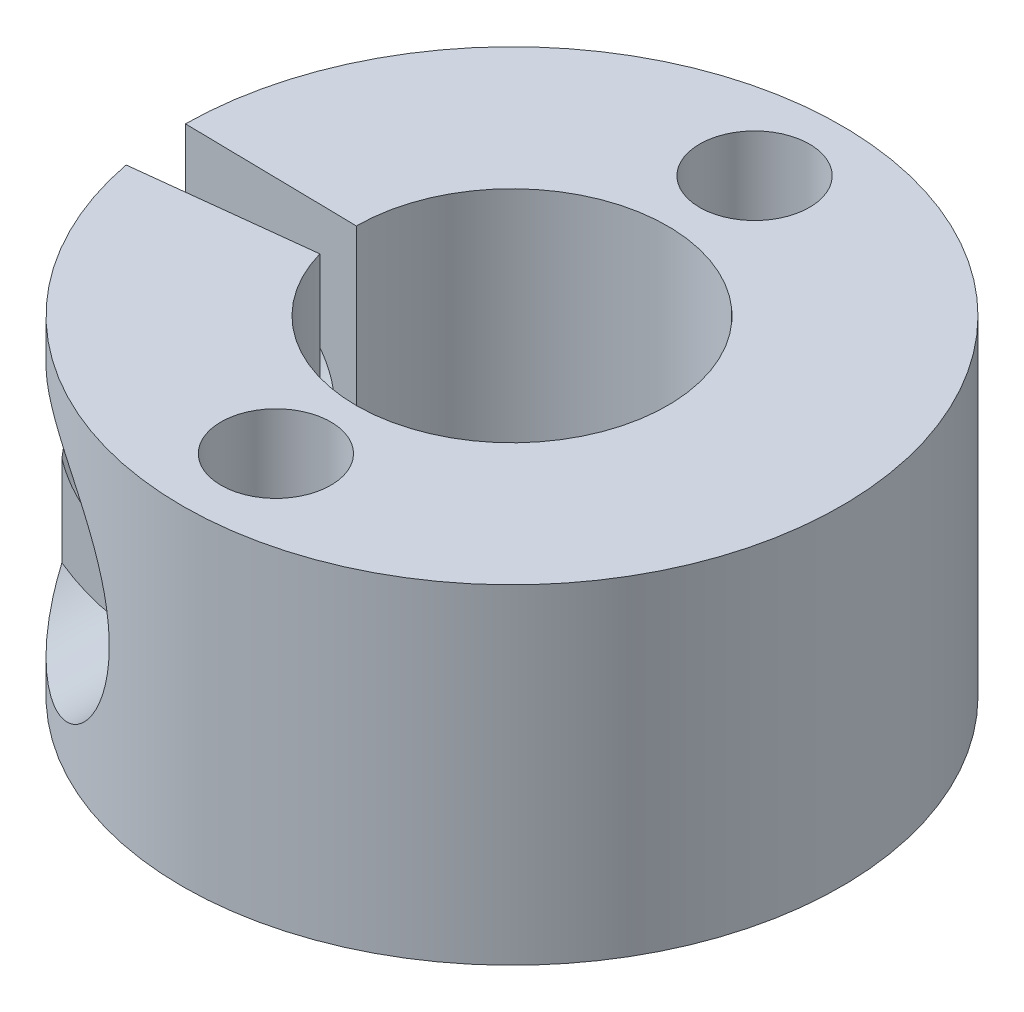
from build123d import *

# Parameters (mm, degrees)
BOSS_EXTRUDE1_DEPTH     = 9
SKETCH2_R               = 1.75
CUT_EXTRUDE1_DEPTH      = 11.651759691
CUT_EXTRUDE1_DEPTH_BACK = 10.276217487
SKETCH3_R               = 3.5
CUT_EXTRUDE2_DEPTH      = 5.5
SKETCH4_R               = 3.5
CUT_EXTRUDE3_DEPTH      = 7
SKETCH5_R               = 1.5
CUT_EXTRUDE4_DEPTH      = 10.0000001


with BuildPart() as part:
    # Sketch1 → Boss-Extrude1 (new body)
    with BuildSketch(Plane(origin=(0, 0, 0), x_dir=(1, 0, 0), z_dir=(0, 1, 0))):
        with BuildLine():
            ThreePointArc((9, 0), (0.040582687, 8.999908502), (-8.99963401, 0.081164549))
            Line((-8.99963401, 0.081164549), (-4.25, 0))
            ThreePointArc((-4.25, 0), (0, 4.25), (4.25, 0))
            ThreePointArc((4.25, 0), (0.585435043, -4.209485219), (-4.088713322, -1.159708311))
            Line((-4.088713322, -1.159708311), (-8.837484751, -1.702604851))
            ThreePointArc((-8.837484751, -1.702604851), (0.855171691, -8.959279066), (9, 0))
        make_face()
    extrude(amount=BOSS_EXTRUDE1_DEPTH)

    # Sketch2 → Cut-Extrude1 (cut, two sides)
    with BuildSketch(Plane(origin=(0.078121964, 0, 0.683340793), x_dir=(-0.993528428, 0, 0.113583725), z_dir=(-0.113583725, 0, -0.993528428))) as cut_extrude1_sk:
        with Locations((6.583828722, 4.5)):
            Circle(SKETCH2_R)
    extrude(amount=CUT_EXTRUDE1_DEPTH, mode=Mode.SUBTRACT)
    extrude(cut_extrude1_sk.sketch, amount=-CUT_EXTRUDE1_DEPTH_BACK, mode=Mode.SUBTRACT)

    # Sketch3 → Cut-Extrude2 (cut)
    with BuildSketch(Plane.XY.offset(10)):
        with Locations((-5.798386902, 4.384929451)):
            Circle(SKETCH3_R)
    extrude(amount=-CUT_EXTRUDE2_DEPTH, mode=Mode.SUBTRACT)

    # Sketch4 → Cut-Extrude3 (cut)
    with BuildSketch(Plane.XY.offset(-10)):
        with Locations((-7.26360584, 4.480644852)):
            Circle(SKETCH4_R)
    extrude(amount=CUT_EXTRUDE3_DEPTH, mode=Mode.SUBTRACT)

    # Sketch5 → Cut-Extrude4 (cut, through all)
    with BuildSketch(Plane(origin=(0, 9, 0), x_dir=(1, 0, 0), z_dir=(0, 1, 0))):
        with Locations((0.035505664, -6.484233459)):
            Circle(SKETCH5_R)
        with Locations((0, 6.625)):
            Circle(SKETCH5_R)
    extrude(amount=-CUT_EXTRUDE4_DEPTH, mode=Mode.SUBTRACT)


solid = part.part
